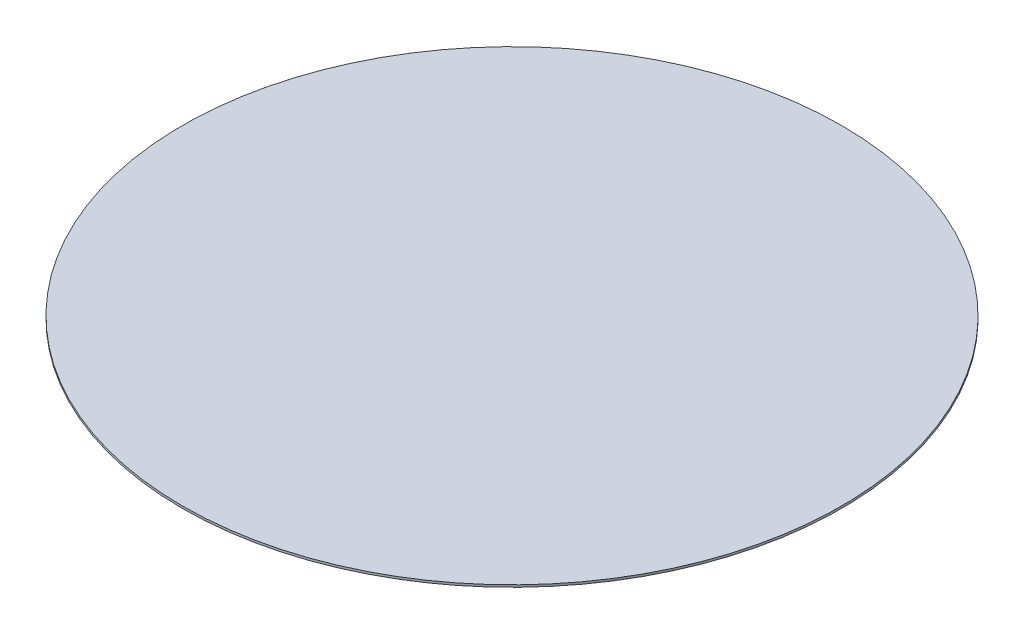
from build123d import *

# Parameters (mm, degrees)
SKETCH1_R           = 150
BOSS_EXTRUDE1_DEPTH = 1


with BuildPart() as part:
    # Sketch1 → Boss-Extrude1 (new body)
    with BuildSketch(Plane(origin=(0, 0, 0), x_dir=(1, 0, 0), z_dir=(0, 1, 0))):
        Circle(SKETCH1_R)
    extrude(amount=BOSS_EXTRUDE1_DEPTH)


solid = part.part
